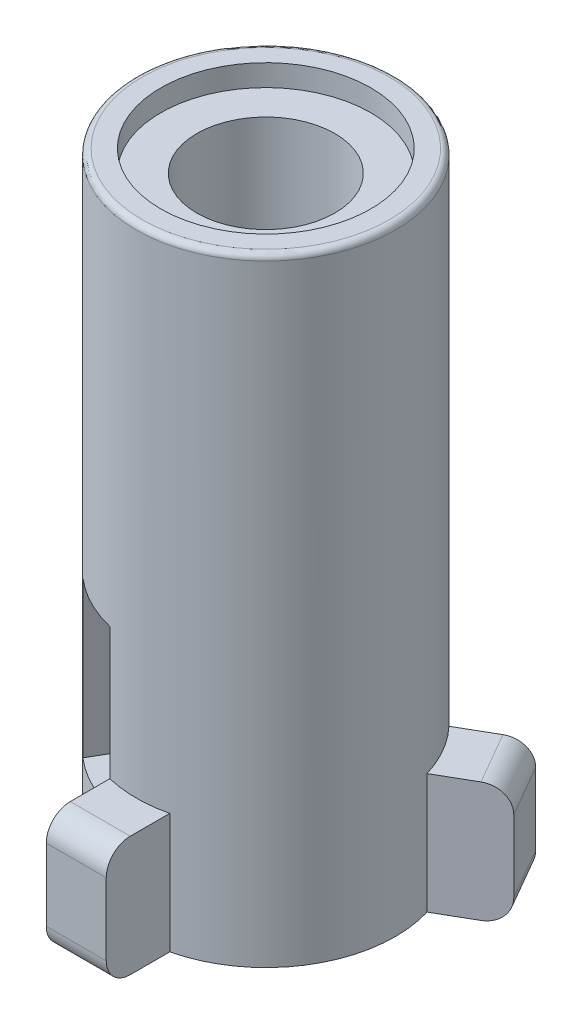
from build123d import *

# Parameters (mm, degrees)
SKETCH1_R           = 5.4
BOSS_EXTRUDE1_DEPTH = 25.75
SKETCH2_W           = 2.5
SKETCH2_H           = 5.463227165
BOSS_EXTRUDE2_DEPTH = 5
FILLET1_R           = 1
FILLET2_R           = 0.25
SKETCH4_R           = 2.875
CUT_EXTRUDE1_DEPTH  = 25.75
SKETCH5_R           = 4.375
CUT_EXTRUDE2_DEPTH  = 0.9
SKETCH6_R           = 4.375
CUT_EXTRUDE3_DEPTH  = 0.9
SKETCH9_W           = 2.6
SKETCH9_H           = 6.5
CUT_EXTRUDE4_DEPTH  = 10


with BuildPart() as part:
    # Sketch1 → Boss-Extrude1 (new body)
    with BuildSketch(Plane(origin=(0, 0, 0), x_dir=(1, 0, 0), z_dir=(0, 1, 0))):
        Circle(SKETCH1_R)
    extrude(amount=BOSS_EXTRUDE1_DEPTH)

    # Sketch2 → Boss-Extrude2 (add)
    with BuildSketch(Plane.XZ):
        Polygon((2.738101985, -0.137468245), (7.46660069, -2.867468245), (6.21660069, -5.032531755), (1.488101985, -2.302531755), align=None)
        with Locations((0, 5.168386418)):
            Rectangle(SKETCH2_W, SKETCH2_H)
        Polygon((-2.738101985, -0.137468245), (-1.488101985, -2.302531755), (-6.21660069, -5.032531755), (-7.46660069, -2.867468245), align=None)
    extrude(amount=-BOSS_EXTRUDE2_DEPTH)

    # Fillet1
    fillet1_edges = [part.edges().sort_by_distance(p)[0] for p in [
        (0, 5, 7.9),
        (0, 0, 7.9),
        (6.84160069, 5, -3.95),
        (6.84160069, 0, -3.95),
        (-6.84160069, 5, -3.95),
        (-6.84160069, 0, -3.95),
    ]]
    fillet(fillet1_edges, radius=FILLET1_R)

    # Fillet2
    fillet2_edges = [part.edges().sort_by_distance(p)[0] for p in [
        (-5.4, 25.75, 0),
    ]]
    fillet(fillet2_edges, radius=FILLET2_R)

    # Sketch4 → Cut-Extrude1 (cut)
    with BuildSketch(Plane.XZ):
        Circle(SKETCH4_R)
    extrude(amount=-CUT_EXTRUDE1_DEPTH, mode=Mode.SUBTRACT)

    # Sketch5 → Cut-Extrude2 (cut)
    with BuildSketch(Plane(origin=(0, 0, 0), x_dir=(-1, 0, 0), z_dir=(0, -1, 0))):
        Circle(SKETCH5_R)
    extrude(amount=-CUT_EXTRUDE2_DEPTH, mode=Mode.SUBTRACT)

    # Sketch6 → Cut-Extrude3 (cut)
    with BuildSketch(Plane(origin=(0, 25.75, 0), x_dir=(1, 0, 0), z_dir=(0, 1, 0))):
        Circle(SKETCH6_R)
    extrude(amount=-CUT_EXTRUDE3_DEPTH, mode=Mode.SUBTRACT)

    # Sketch9 → Cut-Extrude4 (cut)
    with BuildSketch(Plane(origin=(0, 0, 0), x_dir=(0.866025404, 0, 0.5), z_dir=(-0.5, 0, 0.866025404))):
        with Locations((0.244134383, 7.25)):
            Rectangle(SKETCH9_W, SKETCH9_H)
    extrude(amount=CUT_EXTRUDE4_DEPTH, mode=Mode.SUBTRACT)


solid = part.part
